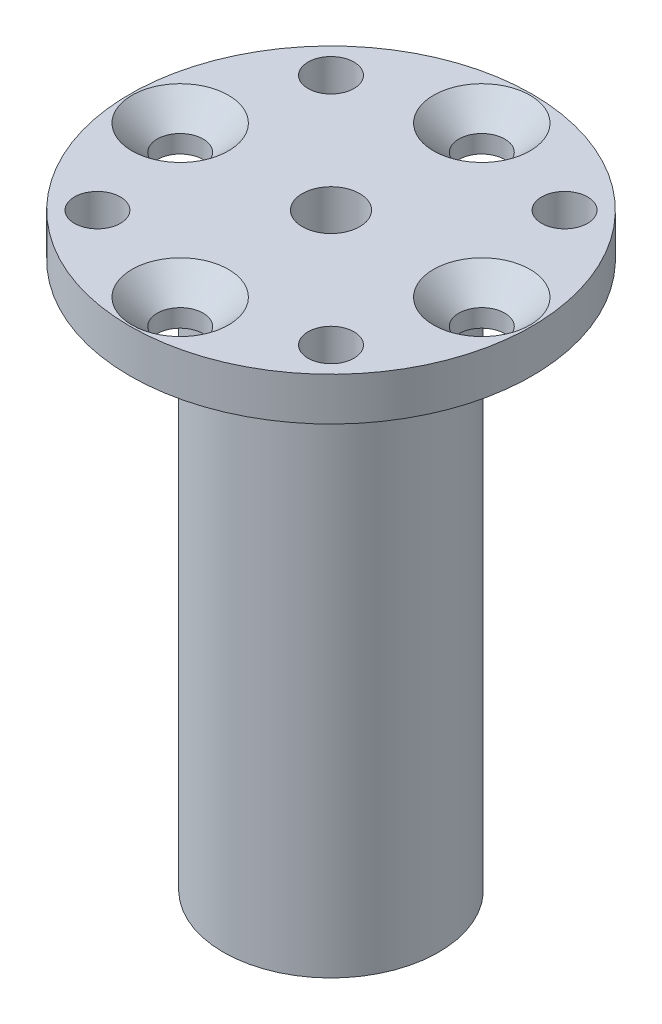
from build123d import *

# Parameters (mm, degrees)
F_4_0_4_DURCHMESSER_BOHRUNG1_D       = 4
F_4_0_4_DURCHMESSER_BOHRUNG1_DEPTH   = 41
KREISMUSTER1_COUNT                   = 3
KREISMUSTER2_COUNT                   = 4
F_3_2_3_2_DURCHMESSER_BOHRUNG1_D     = 3.2
F_3_2_3_2_DURCHMESSER_BOHRUNG1_DEPTH = 3.001
KREISMUSTER3_COUNT                   = 4


with BuildPart() as part:
    # Skizze1 → Rotation1 (revolve)
    with BuildSketch(Plane.XY):
        Polygon((0, 0), (14, 0), (14, -3), (7.5, -3), (7.5, -41), (0, -41), align=None)
    revolve(axis=Axis((0, 9.414893617, 0), (0, -1, 0)))

    # Ø4.0 (4) Durchmesser Bohrung1
    with Locations(Plane(origin=(0, 0, 0), x_dir=(1, 0, 0), z_dir=(0, 1, 0))):
        with Locations((0, 0)):
            Hole(F_4_0_4_DURCHMESSER_BOHRUNG1_D / 2, depth=F_4_0_4_DURCHMESSER_BOHRUNG1_DEPTH)

    # Skizze4 → M3 Gewindebohrung1 (revolve, cut)
    with BuildSketch(Plane(origin=(5.5, -41, 0), x_dir=(0, 0, -1), z_dir=(1, 0, 0))):
        Polygon((0, 0), (0, 12.751075774), (1.25, 12), (1.25, 0), align=None)
    m3_gewindebohrung1 = revolve(axis=Axis((5.5, -47.35, 0), (0, 1, 0)), mode=Mode.SUBTRACT)

    # Kreismuster1: M3 Gewindebohrung1 ×3 about axis
    kreismuster1_axis = Axis((0, 0, 0), (0, 1, 0))
    for i in range(1, KREISMUSTER1_COUNT):
        add(m3_gewindebohrung1.rotate(kreismuster1_axis, i * 360 / KREISMUSTER1_COUNT), mode=Mode.SUBTRACT)

    # Skizze6 → Formsenkung für M3 Senkschraube mit Innensechskant1 (revolve, cut)
    with BuildSketch(Plane(origin=(0, 0, -10.5), x_dir=(0, 0, 1), z_dir=(1, 0, 0))):
        Polygon((0, 0), (0, 3.001), (1.6, 3.001), (1.6, 1.76), (3.36, 0), align=None)
    formsenkung_f_r_m3_senkschraube_mit_inne = revolve(axis=Axis((0, 6.35, -10.5), (0, -1, 0)), mode=Mode.SUBTRACT)

    # Kreismuster2: Formsenkung für M3 Senkschraube mit Innensechskant1 ×4 about axis
    kreismuster2_axis = Axis((0, 0, 0), (0, 1, 0))
    for i in range(1, KREISMUSTER2_COUNT):
        add(formsenkung_f_r_m3_senkschraube_mit_inne.rotate(kreismuster2_axis, i * 360 / KREISMUSTER2_COUNT), mode=Mode.SUBTRACT)

    # Ø3.2 (3.2) Durchmesser Bohrung1
    with Locations(Plane(origin=(0, 0, 0), x_dir=(1, 0, 0), z_dir=(0, 1, 0))):
        with Locations((-8.131727984, 8.131727984)):
            f_3_2_3_2_durchmesser_bohrung1 = Hole(F_3_2_3_2_DURCHMESSER_BOHRUNG1_D / 2, depth=F_3_2_3_2_DURCHMESSER_BOHRUNG1_DEPTH)

    # Kreismuster3: Ø3.2 (3.2) Durchmesser Bohrung1 ×4 about axis
    kreismuster3_axis = Axis((0, 0, 0), (0, 1, 0))
    for i in range(1, KREISMUSTER3_COUNT):
        add(f_3_2_3_2_durchmesser_bohrung1.rotate(kreismuster3_axis, i * 360 / KREISMUSTER3_COUNT), mode=Mode.SUBTRACT)


solid = part.part
